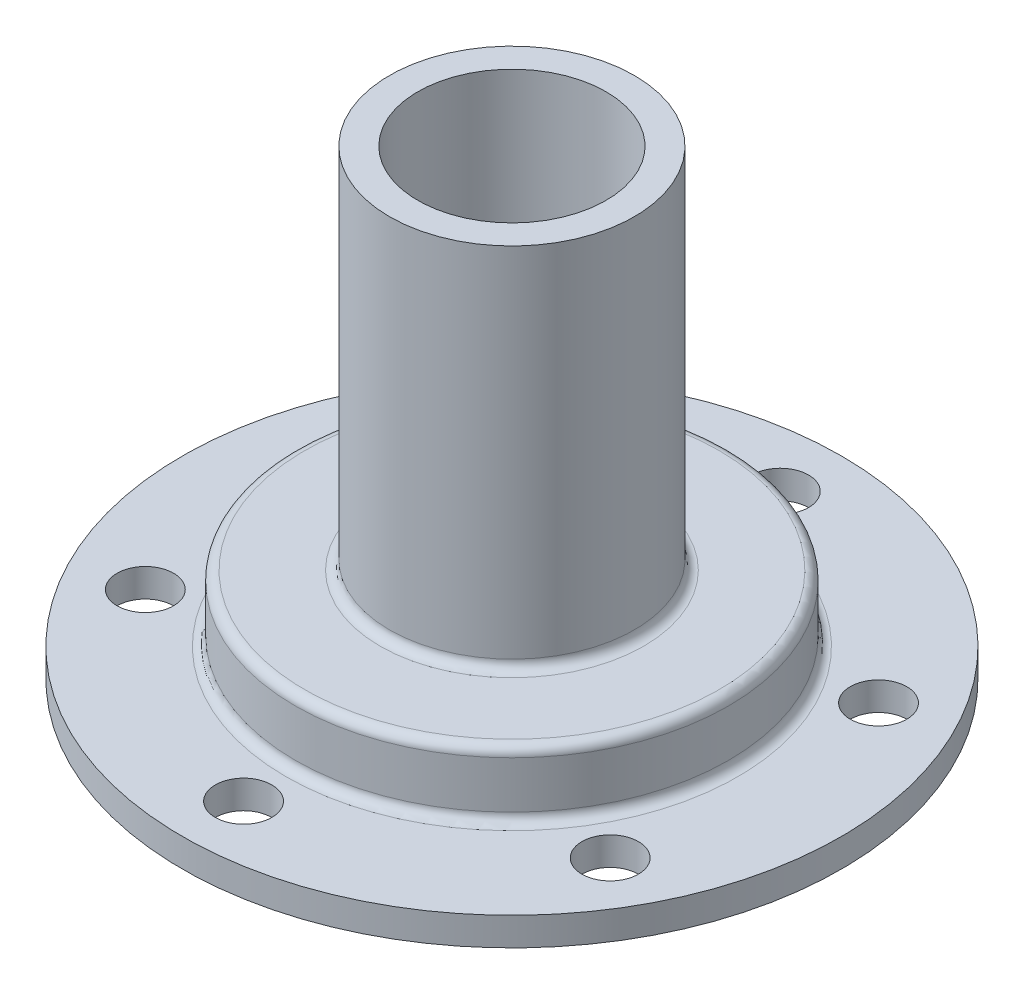
from build123d import *

# Parameters (mm, degrees)
SKETCH_2_R          = 3
CUT_EXTRUDE_1_DEPTH = 4
SKETCH_3_R          = 2.5
CUT_EXTRUDE_2_DEPTH = 36


with BuildPart() as part:
    # 草图1 → 旋转1 (revolve)
    with BuildSketch(Plane.XY):
        with BuildLine():
            Line((20, 0), (35, 0))
            Line((35, 0), (35, 3))
            Line((35, 3), (24, 3))
            ThreePointArc((24, 3), (23.292893219, 3.292893219), (23, 4))
            Line((23, 4), (23, 9))
            ThreePointArc((23, 9), (22.707106781, 9.707106781), (22, 10))
            Line((22, 10), (14, 10))
            ThreePointArc((14, 10), (13.292893219, 10.292893219), (13, 11))
            Line((13, 11), (13, 49))
            Line((13, 49), (10, 49))
            Line((10, 49), (10, 7))
            Line((10, 7), (19, 7))
            ThreePointArc((19, 7), (19.707106781, 6.707106781), (20, 6))
            Line((20, 6), (20, 0))
        make_face()
    revolve(axis=Axis((0, 0, 0), (0, 1, 0)))

    # 草图2 → 切除-拉伸1 (cut, through all)
    with BuildSketch(Plane(origin=(0, 3, 0), x_dir=(1, 0, 0), z_dir=(0, 1, 0))):
        with Locations((0, 28.5)):
            Circle(SKETCH_2_R)
        with Locations((24.681724008, 14.25)):
            Circle(SKETCH_2_R)
        with Locations((24.681724008, -14.25)):
            Circle(SKETCH_2_R)
        with Locations((0, -28.5)):
            Circle(SKETCH_2_R)
        with Locations((-24.681724008, -14.25)):
            Circle(SKETCH_2_R)
        with Locations((-24.681724008, 14.25)):
            Circle(SKETCH_2_R)
    extrude(amount=-CUT_EXTRUDE_1_DEPTH, mode=Mode.SUBTRACT)

    # 草图3 → 切除-拉伸2 (cut, through all)
    with BuildSketch(Plane(origin=(0, 0, 0), x_dir=(0, 0, -1), z_dir=(1, 0, 0))):
        with Locations((0, 34)):
            Circle(SKETCH_3_R)
    extrude(amount=-CUT_EXTRUDE_2_DEPTH, mode=Mode.SUBTRACT)


solid = part.part
